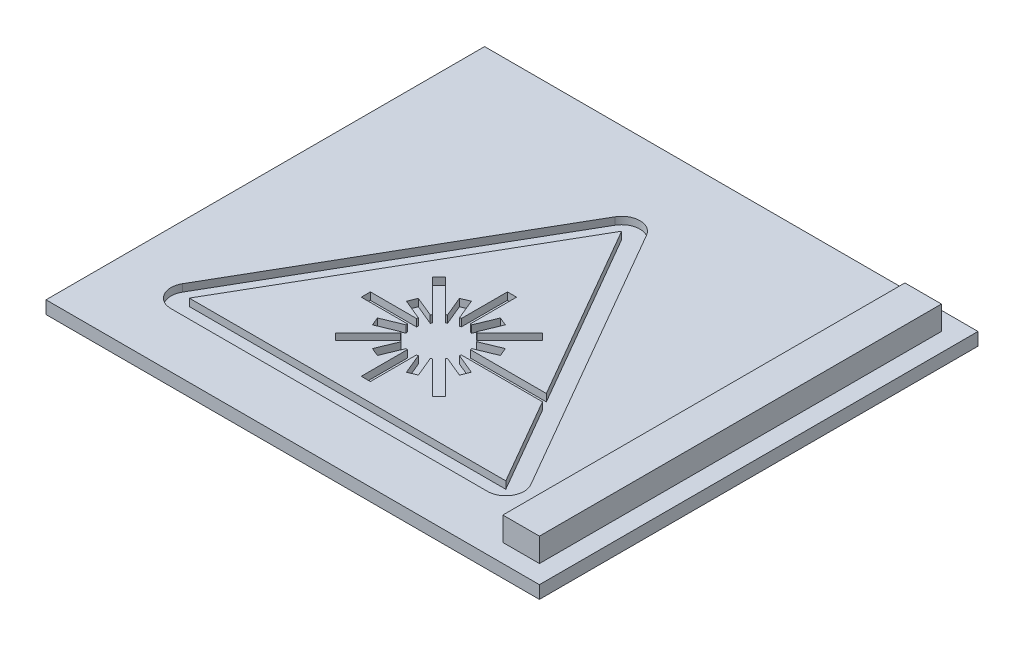
from build123d import *

# Parameters (mm, degrees)
SKETCH1_W           = 26
SKETCH1_H           = 24
BOSS_EXTRUDE1_DEPTH = 0.7
SKETCH2_W           = 2
SKETCH2_H           = 22
BOSS_EXTRUDE2_DEPTH = 1.3
CUT_EXTRUDE2_DEPTH  = 0.4
CUT_EXTRUDE3_DEPTH  = 0.4
SKETCH4_W           = 1
SKETCH4_H           = 24
BOSS_EXTRUDE3_DEPTH = 0.7
CUT_EXTRUDE4_DEPTH  = 0.4


with BuildPart() as part:
    # Sketch1 → Boss-Extrude1 (new body)
    with BuildSketch(Plane(origin=(0, 0, 0), x_dir=(1, 0, 0), z_dir=(0, 1, 0))):
        Rectangle(SKETCH1_W, SKETCH1_H)
    extrude(amount=BOSS_EXTRUDE1_DEPTH)

    # Sketch2 → Boss-Extrude2 (add)
    with BuildSketch(Plane(origin=(0, 0.7, 0), x_dir=(1, 0, 0), z_dir=(0, 1, 0))):
        with Locations((11, 0)):
            Rectangle(SKETCH2_W, SKETCH2_H)
    extrude(amount=BOSS_EXTRUDE2_DEPTH)

    # Sketch3 → Cut-Extrude2 (cut)
    with BuildSketch(Plane(origin=(0, 0.7, 0), x_dir=(1, 0, 0), z_dir=(0, 1, 0))):
        with BuildLine():
            Line((-2.366025404, 7.5), (-11.026279442, -7.5))
            ThreePointArc((-11.026279442, -7.5), (-11.026279442, -8.5), (-10.160254038, -9))
            Line((-10.160254038, -9), (7.160254038, -9))
            ThreePointArc((7.160254038, -9), (8.026279442, -8.5), (8.026279442, -7.5))
            Line((8.026279442, -7.5), (-0.633974596, 7.5))
            ThreePointArc((-0.633974596, 7.5), (-1.5, 8), (-2.366025404, 7.5))
        make_face()
        Polygon((7.160254038, -8), (-1.5, 7), (-10.160254038, -8), align=None, mode=Mode.SUBTRACT)
    extrude(amount=-CUT_EXTRUDE2_DEPTH, mode=Mode.SUBTRACT)

    # Sketch5 → Cut-Extrude3 (cut)
    with BuildSketch(Plane(origin=(0, 0.7, 0), x_dir=(1, 0, 0), z_dir=(0, 1, 0))):
        with BuildLine():
            Line((-4.151650429, -6.00520382), (-2.369048338, -4.222601728))
            ThreePointArc((-2.369048338, -4.222601728), (-2.33335535, -4.247204418), (-2.296966313, -4.270765398))
            Line((-2.296966313, -4.270765398), (-2.756186431, -5.379420837))
            Line((-2.756186431, -5.379420837), (-2.294246665, -5.570762553))
            Line((-2.294246665, -5.570762553), (-1.835026546, -4.462107114))
            ThreePointArc((-1.835026546, -4.462107114), (-1.792635483, -4.471177921), (-1.75, -4.479019946))
            Line((-1.75, -4.479019946), (-1.75, -7))
            Line((-1.75, -7), (-1.25, -7))
            Line((-1.25, -7), (-1.25, -4.479019946))
            ThreePointArc((-1.25, -4.479019946), (-1.207364517, -4.471177921), (-1.164973454, -4.462107114))
            Line((-1.164973454, -4.462107114), (-0.705753335, -5.570762553))
            Line((-0.705753335, -5.570762553), (-0.243813569, -5.379420837))
            Line((-0.243813569, -5.379420837), (-0.703033687, -4.270765398))
            ThreePointArc((-0.703033687, -4.270765398), (-0.66664465, -4.247204418), (-0.630951662, -4.222601728))
            Line((-0.630951662, -4.222601728), (1.151650429, -6.00520382))
            Line((1.151650429, -6.00520382), (1.50520382, -5.651650429))
            Line((1.50520382, -5.651650429), (-0.277398272, -3.869048338))
            ThreePointArc((-0.277398272, -3.869048338), (-0.252795582, -3.83335535), (-0.229234602, -3.796966313))
            Line((-0.229234602, -3.796966313), (0.879420837, -4.256186431))
            Line((0.879420837, -4.256186431), (1.070762553, -3.794246665))
            Line((1.070762553, -3.794246665), (-0.037892886, -3.335026546))
            ThreePointArc((-0.037892886, -3.335026546), (-0.028822079, -3.292635483), (-0.020980054, -3.25))
            Line((-0.020980054, -3.25), (2.5, -3.25))
            Line((2.5, -3.25), (2.5, -2.75))
            Line((2.5, -2.75), (-0.020980054, -2.75))
            ThreePointArc((-0.020980054, -2.75), (-0.028822079, -2.707364517), (-0.037892886, -2.664973454))
            Line((-0.037892886, -2.664973454), (1.070762553, -2.205753335))
            Line((1.070762553, -2.205753335), (0.879420837, -1.743813569))
            Line((0.879420837, -1.743813569), (-0.229234602, -2.203033687))
            ThreePointArc((-0.229234602, -2.203033687), (-0.252795582, -2.16664465), (-0.277398272, -2.130951662))
            Line((-0.277398272, -2.130951662), (1.50520382, -0.348349571))
            Line((1.50520382, -0.348349571), (1.151650429, 0.00520382))
            Line((1.151650429, 0.00520382), (-0.630951662, -1.777398272))
            ThreePointArc((-0.630951662, -1.777398272), (-0.66664465, -1.752795582), (-0.703033687, -1.729234602))
            Line((-0.703033687, -1.729234602), (-0.243813569, -0.620579163))
            Line((-0.243813569, -0.620579163), (-0.705753335, -0.429237447))
            Line((-0.705753335, -0.429237447), (-1.164973454, -1.537892886))
            ThreePointArc((-1.164973454, -1.537892886), (-1.207364517, -1.528822079), (-1.25, -1.520980054))
            Line((-1.25, -1.520980054), (-1.25, 1))
            Line((-1.25, 1), (-1.75, 1))
            Line((-1.75, 1), (-1.75, -1.520980054))
            ThreePointArc((-1.75, -1.520980054), (-1.792635483, -1.528822079), (-1.835026546, -1.537892886))
            Line((-1.835026546, -1.537892886), (-2.294246665, -0.429237447))
            Line((-2.294246665, -0.429237447), (-2.756186431, -0.620579163))
            Line((-2.756186431, -0.620579163), (-2.296966313, -1.729234602))
            ThreePointArc((-2.296966313, -1.729234602), (-2.33335535, -1.752795582), (-2.369048338, -1.777398272))
            Line((-2.369048338, -1.777398272), (-4.151650429, 0.00520382))
            Line((-4.151650429, 0.00520382), (-4.50520382, -0.348349571))
            Line((-4.50520382, -0.348349571), (-2.722601728, -2.130951662))
            ThreePointArc((-2.722601728, -2.130951662), (-2.747204418, -2.16664465), (-2.770765398, -2.203033687))
            Line((-2.770765398, -2.203033687), (-3.879420837, -1.743813569))
            Line((-3.879420837, -1.743813569), (-4.070762553, -2.205753335))
            Line((-4.070762553, -2.205753335), (-2.962107114, -2.664973454))
            ThreePointArc((-2.962107114, -2.664973454), (-2.971177921, -2.707364517), (-2.979019946, -2.75))
            Line((-2.979019946, -2.75), (-5.5, -2.75))
            Line((-5.5, -2.75), (-5.5, -3.25))
            Line((-5.5, -3.25), (-2.979019946, -3.25))
            ThreePointArc((-2.979019946, -3.25), (-2.971177921, -3.292635483), (-2.962107114, -3.335026546))
            Line((-2.962107114, -3.335026546), (-4.070762553, -3.794246665))
            Line((-4.070762553, -3.794246665), (-3.879420837, -4.256186431))
            Line((-3.879420837, -4.256186431), (-2.770765398, -3.796966313))
            ThreePointArc((-2.770765398, -3.796966313), (-2.747204418, -3.83335535), (-2.722601728, -3.869048338))
            Line((-2.722601728, -3.869048338), (-4.50520382, -5.651650429))
            Line((-4.50520382, -5.651650429), (-4.151650429, -6.00520382))
        make_face()
    extrude(amount=-CUT_EXTRUDE3_DEPTH, mode=Mode.SUBTRACT)

    # Sketch4 → Boss-Extrude3 (add)
    with BuildSketch(Plane(origin=(0, 0.7, 0), x_dir=(1, 0, 0), z_dir=(0, 1, 0))):
        with Locations((-13.5, 0)):
            Rectangle(SKETCH4_W, SKETCH4_H)
    extrude(amount=-BOSS_EXTRUDE3_DEPTH)

    # Sketch6 → Cut-Extrude4 (cut)
    with BuildSketch(Plane(origin=(0, 0.7, 0), x_dir=(1, 0, 0), z_dir=(0, 1, 0))):
        Polygon((2.5, -2.75), (4.129165125, -2.75), (4.417840259, -3.25), (2.5, -3.25), align=None)
    extrude(amount=-CUT_EXTRUDE4_DEPTH, mode=Mode.SUBTRACT)


solid = part.part
